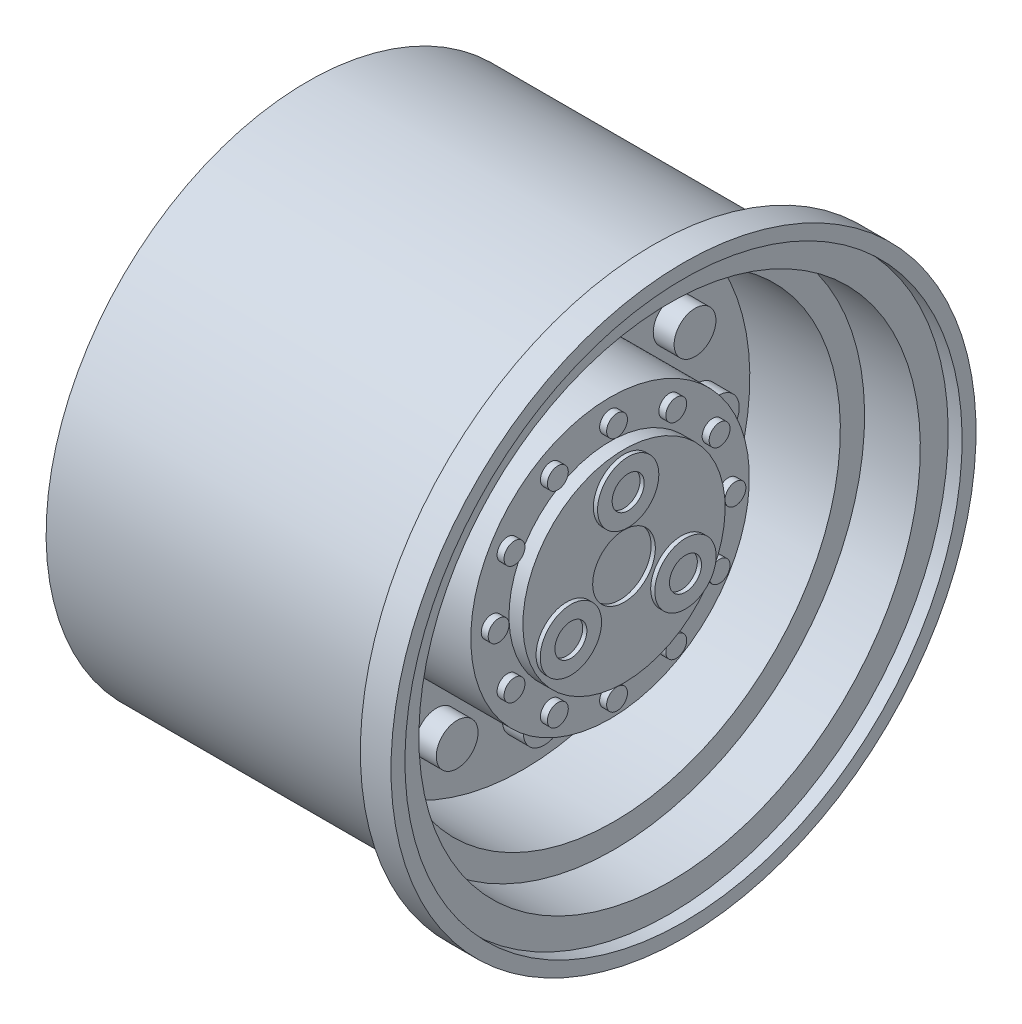
from build123d import *

# Parameters (mm, degrees)
SKETCH2_R           = 3.75
BOSS_EXTRUDE1_DEPTH = 3.75
SKETCH3_R           = 1.875
BOSS_EXTRUDE2_DEPTH = 1.25
SKETCH4_R           = 5.625
CUT_EXTRUDE1_DEPTH  = 0.75
SKETCH5_R           = 5.5
SKETCH5_R_2         = 2.875
BOSS_EXTRUDE3_DEPTH = 0.75
SKETCH7_R           = 1.875
BOSS_EXTRUDE4_DEPTH = 1.25
SKETCH8_R           = 6.25
CUT_EXTRUDE2_DEPTH  = 25


with BuildPart() as part:
    # Sketch1 → Revolve1 (revolve)
    with BuildSketch(Plane.XY):
        Polygon((-22.785, 0), (22.785, 0), (22.785, 18.15), (20.285, 18.15), (20.285, 25), (4.715, 25), (4.715, 40.65), (20.965, 40.65), (20.965, 45), (30.965, 45), (30.965, 50), (33.465, 50), (33.465, 52.5), (27.965, 52.5), (27.965, 46.9), (-34.035, 46.9), (-34.035, 42.5), (-26.535, 42.5), (-26.535, 40.65), (-14.535, 40.65), (-14.535, 22.5), (-19.035, 22.5), (-19.035, 16.25), (-22.785, 16.25), align=None)
    revolve(axis=Axis((-22.785, 0, 0), (1, 0, 0)))

    # Sketch2 → Boss-Extrude1 (add)
    with BuildSketch(Plane(origin=(4.715, 0, 0), x_dir=(0, 0, -1), z_dir=(1, 0, 0))):
        with Locations((0, 31.25)):
            Circle(SKETCH2_R)
        with Locations((15.625, 27.063293868)):
            Circle(SKETCH2_R)
        with Locations((27.063293868, 15.625)):
            Circle(SKETCH2_R)
        with Locations((31.25, 0)):
            Circle(SKETCH2_R)
        with Locations((27.063293868, -15.625)):
            Circle(SKETCH2_R)
        with Locations((15.625, -27.063293868)):
            Circle(SKETCH2_R)
        with Locations((0, -31.25)):
            Circle(SKETCH2_R)
        with Locations((-15.625, -27.063293868)):
            Circle(SKETCH2_R)
        with Locations((-27.063293868, -15.625)):
            Circle(SKETCH2_R)
        with Locations((-31.25, 0)):
            Circle(SKETCH2_R)
        with Locations((-27.063293868, 15.625)):
            Circle(SKETCH2_R)
        with Locations((-15.625, 27.063293868)):
            Circle(SKETCH2_R)
    extrude(amount=BOSS_EXTRUDE1_DEPTH)

    # Sketch3 → Boss-Extrude2 (add)
    with BuildSketch(Plane(origin=(20.285, 0, 0), x_dir=(0, 0, -1), z_dir=(1, 0, 0))):
        with Locations((0, 21.25)):
            Circle(SKETCH3_R)
        with Locations((10.625, 18.40303983)):
            Circle(SKETCH3_R)
        with Locations((18.40303983, 10.625)):
            Circle(SKETCH3_R)
        with Locations((21.25, 0)):
            Circle(SKETCH3_R)
        with Locations((18.40303983, -10.625)):
            Circle(SKETCH3_R)
        with Locations((10.625, -18.40303983)):
            Circle(SKETCH3_R)
        with Locations((0, -21.25)):
            Circle(SKETCH3_R)
        with Locations((-10.625, -18.40303983)):
            Circle(SKETCH3_R)
        with Locations((-18.40303983, -10.625)):
            Circle(SKETCH3_R)
        with Locations((-21.25, 0)):
            Circle(SKETCH3_R)
        with Locations((-18.40303983, 10.625)):
            Circle(SKETCH3_R)
        with Locations((-10.625, 18.40303983)):
            Circle(SKETCH3_R)
    extrude(amount=BOSS_EXTRUDE2_DEPTH)

    # Sketch4 → Cut-Extrude1 (cut)
    with BuildSketch(Plane(origin=(22.785, 0, 0), x_dir=(0, 0, -1), z_dir=(1, 0, 0))):
        Circle(SKETCH4_R)
    extrude(amount=-CUT_EXTRUDE1_DEPTH, mode=Mode.SUBTRACT)

    # Sketch5 → Boss-Extrude3 (add)
    with BuildSketch(Plane(origin=(22.785, 0, 0), x_dir=(0, 0, -1), z_dir=(1, 0, 0))):
        with Locations((0, 11.875)):
            Circle(SKETCH5_R)
        with Locations((0, 11.875)):
            Circle(SKETCH5_R_2, mode=Mode.SUBTRACT)
        with Locations((10.28405167, -5.9375)):
            Circle(SKETCH5_R)
        with Locations((10.28405167, -5.9375)):
            Circle(SKETCH5_R_2, mode=Mode.SUBTRACT)
        with Locations((-10.28405167, -5.9375)):
            Circle(SKETCH5_R)
        with Locations((-10.28405167, -5.9375)):
            Circle(SKETCH5_R_2, mode=Mode.SUBTRACT)
    extrude(amount=BOSS_EXTRUDE3_DEPTH)

    # Sketch7 → Boss-Extrude4 (add)
    with BuildSketch(Plane.ZY.offset(19.035)):
        with Locations((0, 19.05)):
            Circle(SKETCH7_R)
        with Locations((9.525, 16.497783942)):
            Circle(SKETCH7_R)
        with Locations((16.497783942, 9.525)):
            Circle(SKETCH7_R)
        with Locations((19.05, 0)):
            Circle(SKETCH7_R)
        with Locations((16.497783942, -9.525)):
            Circle(SKETCH7_R)
        with Locations((9.525, -16.497783942)):
            Circle(SKETCH7_R)
        with Locations((0, -19.05)):
            Circle(SKETCH7_R)
        with Locations((-9.525, -16.497783942)):
            Circle(SKETCH7_R)
        with Locations((-16.497783942, -9.525)):
            Circle(SKETCH7_R)
        with Locations((-19.05, 0)):
            Circle(SKETCH7_R)
        with Locations((-16.497783942, 9.525)):
            Circle(SKETCH7_R)
        with Locations((-9.525, 16.497783942)):
            Circle(SKETCH7_R)
    extrude(amount=BOSS_EXTRUDE4_DEPTH)

    # Sketch8 → Cut-Extrude2 (cut)
    with BuildSketch(Plane.ZY.offset(22.785)):
        Circle(SKETCH8_R)
    extrude(amount=-CUT_EXTRUDE2_DEPTH, mode=Mode.SUBTRACT)


solid = part.part
